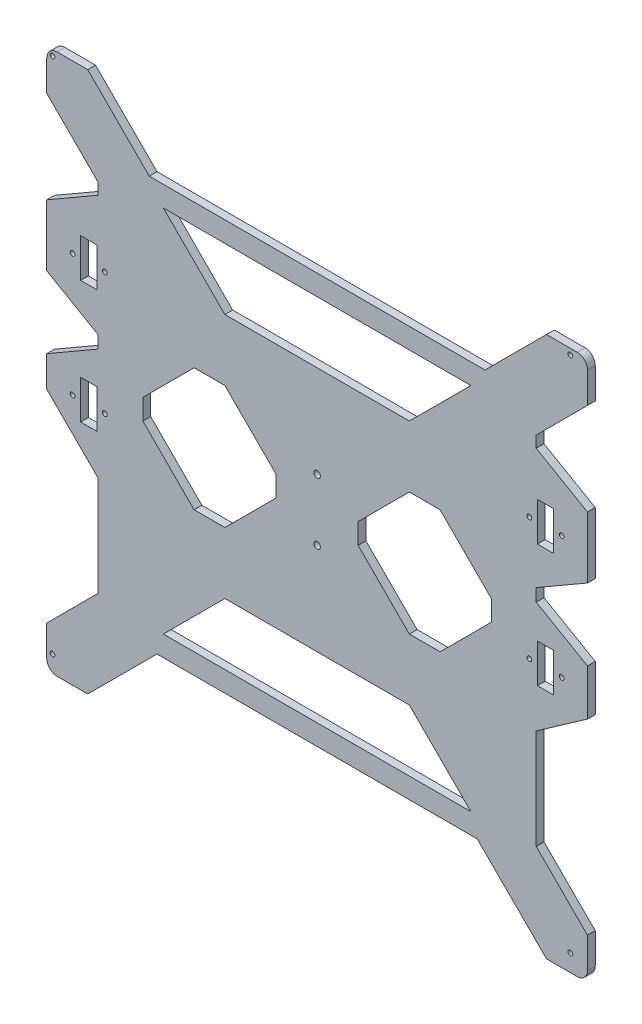
from build123d import *

# Parameters (mm, degrees)
MODEL_R             = 1.4605
MODEL_R_2           = 2
BOSS_EXTRUDE1_DEPTH = 2.413
SKETCH1_W           = 10
SKETCH1_H           = 24
CUT_EXTRUDE1_DEPTH  = 10


with BuildPart() as part:
    # Model → Boss-Extrude1 (new body, symmetric)
    with BuildSketch(Plane.XY):
        with BuildLine():
            Line((-293.081304326, -31.2683), (-261.331304326, -12.937428953))
            Line((-261.331304326, -12.937428953), (-261.331304326, -5.149171047))
            Line((-261.331304326, -5.149171047), (-293.081304326, 13.1817))
            Line((-293.081304326, 13.1817), (-293.081304326, 51.2817))
            Line((-293.081304326, 51.2817), (-261.331304326, 69.612571047))
            Line((-261.331304326, 69.612571047), (-261.331304326, 76.6817))
            Line((-261.331304326, 76.6817), (-293.081304326, 108.4317))
            Line((-293.081304326, 108.4317), (-293.081304326, 127.4817))
            ThreePointArc((-293.081304326, 127.4817), (-291.221432386, 131.971828061), (-286.731304326, 133.8317))
            Line((-286.731304326, 133.8317), (-267.681304326, 133.8317))
            Line((-267.681304326, 133.8317), (-229.581304326, 95.7317))
            Line((-229.581304326, 95.7317), (-21.581304326, 95.7317))
            Line((-21.581304326, 95.7317), (16.518695674, 133.8317))
            Line((16.518695674, 133.8317), (35.568695674, 133.8317))
            ThreePointArc((35.568695674, 133.8317), (40.058823735, 131.971828061), (41.918695674, 127.4817))
            Line((41.918695674, 127.4817), (41.918695674, 108.4317))
            Line((41.918695674, 108.4317), (10.168695674, 76.6817))
            Line((10.168695674, 76.6817), (10.168695674, 69.612571047))
            Line((10.168695674, 69.612571047), (41.918695674, 51.2817))
            Line((41.918695674, 51.2817), (41.918695674, 13.1817))
            Line((41.918695674, 13.1817), (10.168695674, -5.149171047))
            Line((10.168695674, -5.149171047), (10.168695674, -12.937428953))
            Line((10.168695674, -12.937428953), (41.918695674, -31.2683))
            Line((41.918695674, -31.2683), (41.918695674, -59.836710662))
            Line((41.918695674, -59.836710662), (12.864640386, -80.18057919))
            Line((12.864640386, -80.18057919), (10.168695674, -82.0683))
            Line((10.168695674, -82.0683), (10.168695674, -144.0183))
            Line((10.168695674, -144.0183), (41.918695674, -175.7683))
            Line((41.918695674, -175.7683), (41.918695674, -194.8183))
            ThreePointArc((41.918695674, -194.8183), (40.058823735, -199.308428061), (35.568695674, -201.1683))
            Line((35.568695674, -201.1683), (16.518695674, -201.1683))
            Line((16.518695674, -201.1683), (-26.381304326, -158.2683))
            Line((-26.381304326, -158.2683), (-224.781304326, -158.2683))
            Line((-224.781304326, -158.2683), (-267.681304326, -201.1683))
            Line((-267.681304326, -201.1683), (-286.731304326, -201.1683))
            ThreePointArc((-286.731304326, -201.1683), (-291.221432386, -199.308428061), (-293.081304326, -194.8183))
            Line((-293.081304326, -194.8183), (-293.081304326, -175.7683))
            Line((-293.081304326, -175.7683), (-261.331304326, -144.0183))
            Line((-261.331304326, -144.0183), (-261.331304326, -82.0683))
            Line((-261.331304326, -82.0683), (-293.081304326, -50.3183))
            Line((-293.081304326, -50.3183), (-293.081304326, -31.2683))
        make_face()
        with Locations((-289.525304326, -190.6025)):
            Circle(MODEL_R, mode=Mode.SUBTRACT)
        with Locations((31.352895674, -190.6025)):
            Circle(MODEL_R, mode=Mode.SUBTRACT)
        with Locations((31.352895674, 130.2757)):
            Circle(MODEL_R, mode=Mode.SUBTRACT)
        with Locations((-289.525304326, 130.2757)):
            Circle(MODEL_R, mode=Mode.SUBTRACT)
        with Locations((-277.081304256, -45.4288)):
            Circle(MODEL_R, mode=Mode.SUBTRACT)
        with Locations((-257.081304256, -45.4288)):
            Circle(MODEL_R, mode=Mode.SUBTRACT)
        with Locations((25.918695604, -45.4288)):
            Circle(MODEL_R, mode=Mode.SUBTRACT)
        with Locations((5.918695604, -45.4288)):
            Circle(MODEL_R, mode=Mode.SUBTRACT)
        with Locations((25.918695604, 30.5682)):
            Circle(MODEL_R, mode=Mode.SUBTRACT)
        with Locations((5.918695604, 30.5682)):
            Circle(MODEL_R, mode=Mode.SUBTRACT)
        with Locations((-257.081304256, 30.5682)):
            Circle(MODEL_R, mode=Mode.SUBTRACT)
        with Locations((-277.081304256, 30.5682)):
            Circle(MODEL_R, mode=Mode.SUBTRACT)
        with Locations((-125.581304326, -12.2183)):
            Circle(MODEL_R_2, mode=Mode.SUBTRACT)
        with Locations((-125.581304326, -50.3183)):
            Circle(MODEL_R_2, mode=Mode.SUBTRACT)
        Polygon((-30.331304326, -145.5683), (-68.431304326, -107.4683), (-182.731304326, -107.4683), (-220.831304326, -145.5683), align=None, mode=Mode.SUBTRACT)
        Polygon((-220.831304326, 83.0317), (-182.731304326, 44.9317), (-68.431304326, 44.9317), (-30.331304326, 83.0317), align=None, mode=Mode.SUBTRACT)
        Polygon((-201.781304326, -69.3683), (-233.531304326, -37.6183), (-233.531304326, -24.9183), (-201.781304326, 6.8317), (-182.731304326, 6.8317), (-150.981304326, -24.9183), (-150.981304326, -37.6183), (-182.731304326, -69.3683), align=None, mode=Mode.SUBTRACT)
        Polygon((-100.181304326, -37.6183), (-100.181304326, -24.9183), (-68.431304326, 6.8317), (-49.381304326, 6.8317), (-17.631304326, -24.9183), (-17.631304326, -37.6183), (-49.381304326, -69.3683), (-68.431304326, -69.3683), align=None, mode=Mode.SUBTRACT)
    extrude(amount=BOSS_EXTRUDE1_DEPTH, both=True)

    # Sketch1 → Cut-Extrude1 (cut)
    with BuildSketch(Plane.XY.offset(2.413)):
        with Locations((-267.081304256, -45.4288)):
            Rectangle(SKETCH1_W, SKETCH1_H)
        with Locations((-267.081304256, 30.5712)):
            Rectangle(SKETCH1_W, SKETCH1_H)
        with Locations((15.918695604, 30.5712)):
            Rectangle(SKETCH1_W, SKETCH1_H)
        with Locations((15.918695604, -45.4288)):
            Rectangle(SKETCH1_W, SKETCH1_H)
    extrude(amount=-CUT_EXTRUDE1_DEPTH, mode=Mode.SUBTRACT)


solid = part.part
